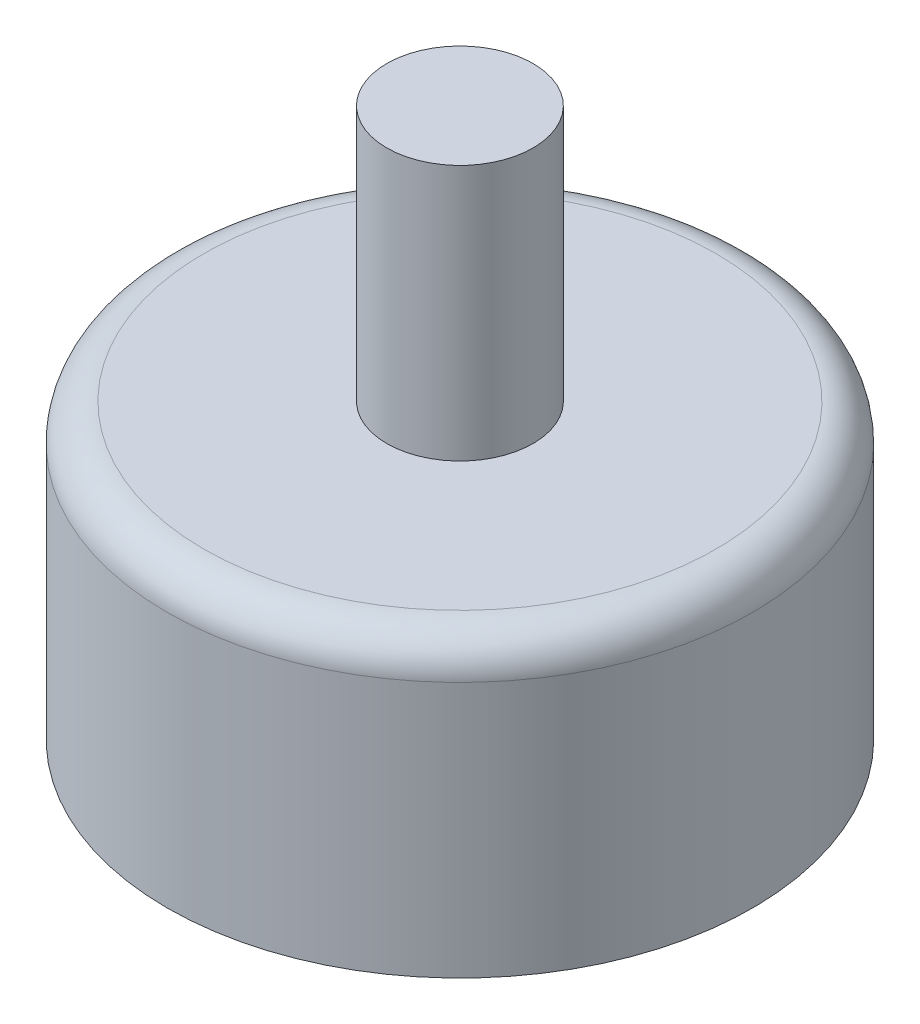
from build123d import *

# Parameters (mm, degrees)
SKETCH1_R           = 20
BOSS_EXTRUDE1_DEPTH = 20
SKETCH2_R           = 5
BOSS_EXTRUDE2_DEPTH = 17.5
FILLET1_R           = 2.5


with BuildPart() as part:
    # Sketch1 → Boss-Extrude1 (new body)
    with BuildSketch(Plane(origin=(0, 0, 0), x_dir=(1, 0, 0), z_dir=(0, 1, 0))):
        Circle(SKETCH1_R)
    extrude(amount=BOSS_EXTRUDE1_DEPTH)

    # Sketch2 → Boss-Extrude2 (add)
    with BuildSketch(Plane(origin=(0, 20, 0), x_dir=(1, 0, 0), z_dir=(0, 1, 0))):
        Circle(SKETCH2_R)
    extrude(amount=BOSS_EXTRUDE2_DEPTH)

    # Fillet1
    fillet1_edges = [part.edges().sort_by_distance(p)[0] for p in [
        (-20, 20, 0),
    ]]
    fillet(fillet1_edges, radius=FILLET1_R)


solid = part.part
